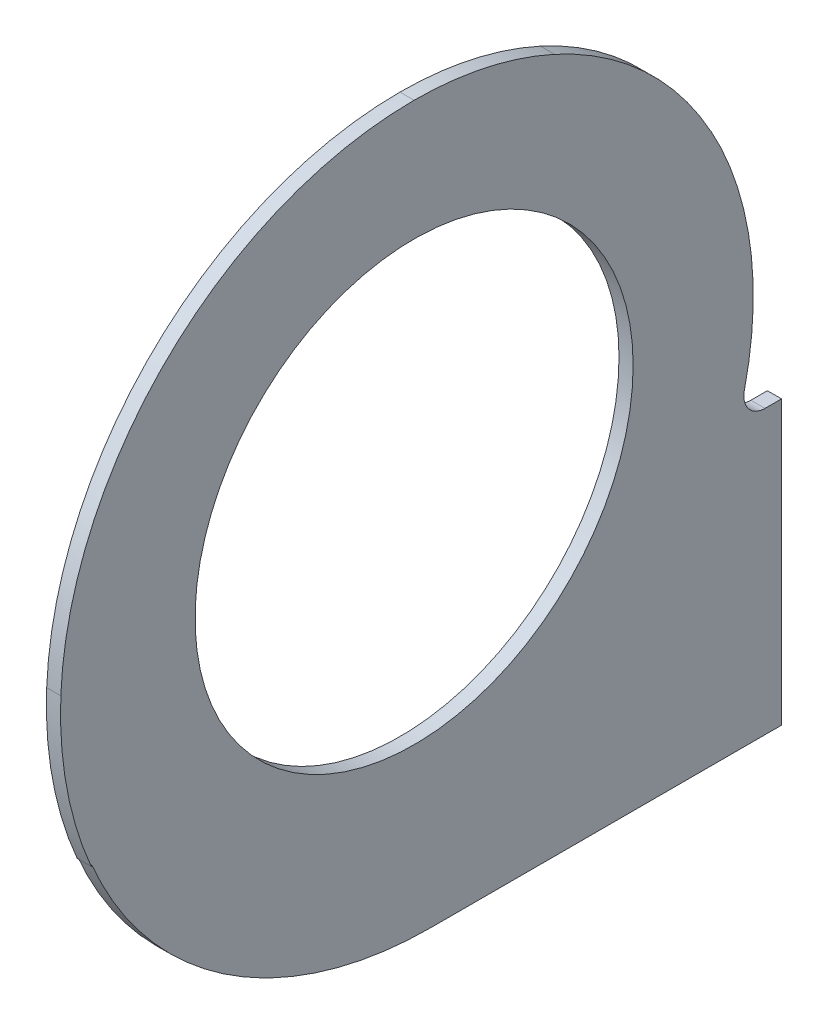
from build123d import *

# Parameters (mm, degrees)
BOSS_EXTRUDE1_DEPTH               = 11.5
BOSS_EXTRUDE2_DEPTH               = 11.5
SKETCH3_W                         = 11.5
SKETCH3_H                         = 20
BOSS_EXTRUDE3_DEPTH               = 2.000101203
CUT_EXTRUDE1_DEPTH                = 10.5
BOSS_EXTRUDE4_DEPTH               = 2
BOSS_EXTRUDE5_DEPTH               = 1
CUT_EXTRUDE2_DEPTH                = 10.5
CUT_EXTRUDE3_DEPTH                = 2
CUT_EXTRUDE4_DEPTH                = 0.5
CUT_EXTRUDE5_DEPTH                = 0.5
CUT_EXTRUDE6_DEPTH                = 0.5
CUT_EXTRUDE7_DEPTH                = 0.5
CUT_EXTRUDE8_DEPTH                = 0.5
CUT_EXTRUDE9_DEPTH                = 0.5
CUT_EXTRUDE10_DEPTH               = 0.5
CUT_EXTRUDE11_DEPTH               = 0.5
SKETCH17_W                        = 0.1
SKETCH17_H                        = 10.000000149
F_3_5_3_5_DIAMETER_HOLE1_D        = 3.5
F_3_5_3_5_DIAMETER_HOLE1_DEPTH    = 14.5
TAP_DRILL_FOR_M30_HELICOIL1_D     = 31
TAP_DRILL_FOR_M30_HELICOIL1_DEPTH = 1
FILLET1_R                         = 1.5
FILLET2_R                         = 2.5
SKETCH22_W                        = 77.458890367
SKETCH22_H                        = 66.182059073
CUT_EXTRUDE12_DEPTH               = 22
CUT_EXTRUDE13_DEPTH               = 22


with BuildPart() as part:
    # Sketch1 → Boss-Extrude1 (new body)
    with BuildSketch(Plane(origin=(14.5, 0, 0), x_dir=(0, 0, -1), z_dir=(1, 0, 0))):
        with BuildLine():
            Line((23.999898797, -14.052218991), (23.999898797, -7.3))
            Line((23.999898797, -7.3), (22.862851966, -7.3))
            ThreePointArc((22.862851966, -7.3), (23.515848466, 4.796339325), (18.177699617, 15.670712703))
            Line((18.177699617, 15.670712703), (20.247987256, 18.013406611))
            ThreePointArc((20.247987256, 18.013406611), (19.986593389, 22.247987256), (15.752012744, 21.986593389))
            Line((15.752012744, 21.986593389), (13.722435262, 19.689966239))
            ThreePointArc((13.722435262, 19.689966239), (7.191690005, 22.897152549), (0, 24))
            ThreePointArc((0, 24), (-17.327723451, 17.028878595), (-25, 0))
            ThreePointArc((-25, 0), (-23.695001808, -9.306968083), (-19.193077259, -17.556534771))
            Line((-19.193077259, -17.556534771), (-22.247987256, -21.013406611))
            ThreePointArc((-22.247987256, -21.013406611), (-21.986593389, -25.247987256), (-17.752012744, -24.986593389))
            Line((-17.752012744, -24.986593389), (-14.906270141, -21.766410971))
            ThreePointArc((-14.906270141, -21.766410971), (6.309457693, -26.79912492), (23.999898797, -14.052218991))
        make_face()
    extrude(amount=-BOSS_EXTRUDE1_DEPTH)

    # Sketch2 → Boss-Extrude2 (add)
    with BuildSketch(Plane(origin=(14.5, 0, 0), x_dir=(0, 0, -1), z_dir=(1, 0, 0))):
        with BuildLine():
            Line((1.208, -27.3), (23.999898797, -27.3))
            Line((23.999898797, -27.3), (23.999898797, -14.052218991))
            ThreePointArc((23.999898797, -14.052218991), (14.389183107, -23.747481674), (1.208, -27.3))
        make_face()
    extrude(amount=-BOSS_EXTRUDE2_DEPTH)

    # Sketch3 → Boss-Extrude3 (add)
    with BuildSketch(Plane(origin=(0, 0, -23.999898797), x_dir=(-1, 0, 0), z_dir=(0, 0, -1))):
        with Locations((-8.75, -17.3)):
            Rectangle(SKETCH3_W, SKETCH3_H)
    extrude(amount=BOSS_EXTRUDE3_DEPTH)

    # Sketch4 → Cut-Extrude1 (cut)
    with BuildSketch(Plane.ZY.offset(-3)):
        with BuildLine():
            Line((-2, 22.912878475), (-2, 11))
            Line((-2, 11), (2.00000006, 11))
            Line((2.00000006, 11), (2.00000006, 22.916594135))
            ThreePointArc((2.00000006, 22.916594135), (1.000869219, 22.979139476), (0, 23))
            ThreePointArc((0, 23), (-1.00094832, 22.978209296), (-2, 22.912878475))
        make_face()
    extrude(amount=-CUT_EXTRUDE1_DEPTH, mode=Mode.SUBTRACT)

    # Sketch5 → Boss-Extrude4 (add)
    with BuildSketch(Plane.ZY.offset(-3)):
        with BuildLine():
            Line((-2, 23.916521486), (-2, 11))
            Line((-2, 11), (2.00000006, 11))
            Line((2.00000006, 11), (2.00000006, 23.919938516))
            ThreePointArc((2.00000006, 23.919938516), (18.03582173, 16.321347476), (25, 0))
            ThreePointArc((25, 0), (23.695001808, -9.306968083), (19.193077259, -17.556534771))
            Line((19.193077259, -17.556534771), (22.247987256, -21.013406611))
            ThreePointArc((22.247987256, -21.013406611), (21.986593389, -25.247987256), (17.752012744, -24.986593389))
            Line((17.752012744, -24.986593389), (14.906270141, -21.766410971))
            ThreePointArc((14.906270141, -21.766410971), (7.31095401, -25.878060536), (-1.208, -27.3))
            Line((-1.208, -27.3), (-26, -27.3))
            Line((-26, -27.3), (-26, -7.3))
            Line((-26, -7.3), (-22.862851966, -7.3))
            ThreePointArc((-22.862851966, -7.3), (-23.515848466, 4.796339325), (-18.177699617, 15.670712703))
            Line((-18.177699617, 15.670712703), (-20.247987256, 18.013406611))
            ThreePointArc((-20.247987256, 18.013406611), (-19.986593389, 22.247987256), (-15.752012744, 21.986593389))
            Line((-15.752012744, 21.986593389), (-13.722435262, 19.689966239))
            ThreePointArc((-13.722435262, 19.689966239), (-8.140312338, 22.577318597), (-2, 23.916521486))
        make_face()
    extrude(amount=BOSS_EXTRUDE4_DEPTH)

    # Sketch6 → Boss-Extrude5 (add)
    with BuildSketch(Plane.ZY.offset(-1)):
        with BuildLine():
            Line((-2, 23.916521486), (-2, 11))
            Line((-2, 11), (2.00000006, 11))
            Line((2.00000006, 11), (2.00000006, 23.919938516))
            ThreePointArc((2.00000006, 23.919938516), (18.03582173, 16.321347476), (25, 0))
            ThreePointArc((25, 0), (23.695001808, -9.306968083), (19.193077259, -17.556534771))
            Line((19.193077259, -17.556534771), (22.247987256, -21.013406611))
            ThreePointArc((22.247987256, -21.013406611), (21.986593389, -25.247987256), (17.752012744, -24.986593389))
            Line((17.752012744, -24.986593389), (14.906270141, -21.766410971))
            ThreePointArc((14.906270141, -21.766410971), (7.31095401, -25.878060536), (-1.208, -27.3))
            Line((-1.208, -27.3), (-26, -27.3))
            Line((-26, -27.3), (-26, -7.3))
            Line((-26, -7.3), (-22.862851966, -7.3))
            ThreePointArc((-22.862851966, -7.3), (-23.515848466, 4.796339325), (-18.177699617, 15.670712703))
            Line((-18.177699617, 15.670712703), (-20.247987256, 18.013406611))
            ThreePointArc((-20.247987256, 18.013406611), (-19.986593389, 22.247987256), (-15.752012744, 21.986593389))
            Line((-15.752012744, 21.986593389), (-13.722435262, 19.689966239))
            ThreePointArc((-13.722435262, 19.689966239), (-8.140312338, 22.577318597), (-2, 23.916521486))
        make_face()
    extrude(amount=BOSS_EXTRUDE5_DEPTH)

    # Sketch7 → Cut-Extrude2 (cut)
    with BuildSketch(Plane(origin=(13.5, 0, 0), x_dir=(0, 0, -1), z_dir=(1, 0, 0))):
        with BuildLine():
            Line((2, 22.912878475), (2, 11))
            Line((2, 11), (-2.00000006, 11))
            Line((-2.00000006, 11), (-2.00000006, 22.916594135))
            ThreePointArc((-2.00000006, 22.916594135), (-17.342759411, 15.599308966), (-24.000832639, -0.040799334))
            ThreePointArc((-24.000832639, -0.040799334), (-16.992486688, -18.54262722), (1.208, -26.3))
            Line((1.208, -26.3), (26, -26.3))
            Line((26, -26.3), (26, -8.3))
            Line((26, -8.3), (21.450174824, -8.3))
            ThreePointArc((21.450174824, -8.3), (19.520210565, 12.163937664), (2, 22.912878475))
        make_face()
    extrude(amount=-CUT_EXTRUDE2_DEPTH, mode=Mode.SUBTRACT)

    # Sketch8 → Cut-Extrude3 (cut)
    with BuildSketch(Plane(origin=(3, 0, 0), x_dir=(0, 0, -1), z_dir=(1, 0, 0))):
        with BuildLine():
            Line((2, 22.912878475), (2, 11))
            Line((2, 11), (-2.00000006, 11))
            Line((-2.00000006, 11), (-2.00000006, 22.916594135))
            ThreePointArc((-2.00000006, 22.916594135), (-17.342759411, 15.599308966), (-24.000832639, -0.040799334))
            ThreePointArc((-24.000832639, -0.040799334), (-16.992486688, -18.54262722), (1.208, -26.3))
            Line((1.208, -26.3), (26, -26.3))
            Line((26, -26.3), (26, -8.3))
            Line((26, -8.3), (21.450174824, -8.3))
            ThreePointArc((21.450174824, -8.3), (19.520210565, 12.163937664), (2, 22.912878475))
        make_face()
    extrude(amount=-CUT_EXTRUDE3_DEPTH, mode=Mode.SUBTRACT)

    # Sketch9 → Cut-Extrude4 (cut)
    with BuildSketch(Plane.ZY):
        with BuildLine():
            Line((-0.5, -22.994564575), (-0.5, -10.988630488))
            ThreePointArc((-0.5, -10.988630488), (-4.209517756, -10.162674858), (-7.416581743, -8.123688525))
            Line((-7.416581743, -8.123688525), (-15.906059151, -16.613165932))
            ThreePointArc((-15.906059151, -16.613165932), (-8.801718944, -21.249229248), (-0.5, -22.994564575))
        make_face()
    extrude(amount=-CUT_EXTRUDE4_DEPTH, mode=Mode.SUBTRACT)

    # Sketch10 → Cut-Extrude5 (cut)
    with BuildSketch(Plane.ZY):
        with BuildLine():
            Line((-15.906059151, 16.613165932), (-7.416581743, 8.123688525))
            ThreePointArc((-7.416581743, 8.123688525), (-5.351481429, 9.610496684), (-3, 10.583005244))
            Line((-3, 10.583005244), (-3, 22.803508502))
            ThreePointArc((-3, 22.803508502), (-9.946851433, 20.737891565), (-15.906059151, 16.613165932))
        make_face()
    extrude(amount=-CUT_EXTRUDE5_DEPTH, mode=Mode.SUBTRACT)

    # Sketch11 → Cut-Extrude6 (cut)
    with BuildSketch(Plane.ZY):
        with BuildLine():
            Line((16.613165932, 15.906059151), (8.123688525, 7.416581743))
            ThreePointArc((8.123688525, 7.416581743), (10.162674858, 4.209517756), (10.988630488, 0.5))
            Line((10.988630488, 0.5), (22.994564575, 0.5))
            ThreePointArc((22.994564575, 0.5), (21.249229248, 8.801718944), (16.613165932, 15.906059151))
        make_face()
    extrude(amount=-CUT_EXTRUDE6_DEPTH, mode=Mode.SUBTRACT)

    # Sketch12 → Cut-Extrude7 (cut)
    with BuildSketch(Plane.ZY):
        with BuildLine():
            Line((-16.613165932, -15.906059151), (-8.123688525, -7.416581743))
            ThreePointArc((-8.123688525, -7.416581743), (-10.162674858, -4.209517756), (-10.988630488, -0.5))
            Line((-10.988630488, -0.5), (-22.994564575, -0.5))
            ThreePointArc((-22.994564575, -0.5), (-21.249229248, -8.801718944), (-16.613165932, -15.906059151))
        make_face()
    extrude(amount=-CUT_EXTRUDE7_DEPTH, mode=Mode.SUBTRACT)

    # Sketch13 → Cut-Extrude8 (cut)
    with BuildSketch(Plane.ZY):
        with BuildLine():
            Line((15.906059151, -16.613165932), (7.416581743, -8.123688525))
            ThreePointArc((7.416581743, -8.123688525), (4.209517756, -10.162674858), (0.5, -10.988630488))
            Line((0.5, -10.988630488), (0.5, -22.994564575))
            ThreePointArc((0.5, -22.994564575), (8.801718944, -21.249229248), (15.906059151, -16.613165932))
        make_face()
    extrude(amount=-CUT_EXTRUDE8_DEPTH, mode=Mode.SUBTRACT)

    # Sketch14 → Cut-Extrude9 (cut)
    with BuildSketch(Plane.ZY):
        with BuildLine():
            Line((3, 22.803508502), (3, 10.583005244))
            ThreePointArc((3, 10.583005244), (5.351481429, 9.610496684), (7.416581743, 8.123688525))
            Line((7.416581743, 8.123688525), (15.906059151, 16.613165932))
            ThreePointArc((15.906059151, 16.613165932), (9.946851433, 20.737891565), (3, 22.803508502))
        make_face()
    extrude(amount=-CUT_EXTRUDE9_DEPTH, mode=Mode.SUBTRACT)

    # Sketch15 → Cut-Extrude10 (cut)
    with BuildSketch(Plane.ZY):
        with BuildLine():
            Line((8.123688525, -7.416581743), (16.613165932, -15.906059151))
            ThreePointArc((16.613165932, -15.906059151), (21.249229248, -8.801718944), (22.994564575, -0.5))
            Line((22.994564575, -0.5), (10.988630488, -0.5))
            ThreePointArc((10.988630488, -0.5), (10.162674858, -4.209517756), (8.123688525, -7.416581743))
        make_face()
    extrude(amount=-CUT_EXTRUDE10_DEPTH, mode=Mode.SUBTRACT)

    # Sketch16 → Cut-Extrude11 (cut)
    with BuildSketch(Plane.ZY):
        with BuildLine():
            Line((-22.994564575, 0.5), (-10.988630488, 0.5))
            ThreePointArc((-10.988630488, 0.5), (-10.162674858, 4.209517756), (-8.123688525, 7.416581743))
            Line((-8.123688525, 7.416581743), (-16.613165932, 15.906059151))
            ThreePointArc((-16.613165932, 15.906059151), (-21.249229248, 8.801718944), (-22.994564575, 0.5))
        make_face()
    extrude(amount=-CUT_EXTRUDE11_DEPTH, mode=Mode.SUBTRACT)

    # Sketch17 → Cut-Revolve1 (revolve, cut)
    with BuildSketch(Plane(origin=(0, 0, 0), x_dir=(1, 0, 0), z_dir=(0, 1, 0))):
        with Locations((0.05, 5.000000074)):
            Rectangle(SKETCH17_W, SKETCH17_H)
    revolve(axis=Axis((0, 0, 0), (1, 0, 0)), mode=Mode.SUBTRACT)

    # Ø3.5 (3.5) Diameter Hole1
    with Locations(Plane.ZY):
        with Locations((-18, 20), (20, -23)):
            Hole(F_3_5_3_5_DIAMETER_HOLE1_D / 2, depth=F_3_5_3_5_DIAMETER_HOLE1_DEPTH)

    # Tap Drill for M30 Helicoil1
    with Locations(Plane(origin=(14.5, 0, 0), x_dir=(0, 0, -1), z_dir=(1, 0, 0))):
        with Locations((0, 0)):
            Hole(TAP_DRILL_FOR_M30_HELICOIL1_D / 2, depth=TAP_DRILL_FOR_M30_HELICOIL1_DEPTH)

    # Fillet1
    fillet1_edges = [part.edges().sort_by_distance(p)[0] for p in [
        (7.25, -7.3, -22.862851966),
    ]]
    fillet(fillet1_edges, radius=FILLET1_R)

    # Fillet2
    fillet2_edges = [part.edges().sort_by_distance(p)[0] for p in [
        (7.25, -8.3, -21.450174824),
        (7.25, -21.766410971, 14.906270141),
        (7.25, -17.556534771, 19.193077259),
        (7.25, 19.689966239, -13.722435262),
        (7.25, 15.670712703, -18.177699617),
    ]]
    fillet(fillet2_edges, radius=FILLET2_R)

    # Sketch22 → Cut-Extrude12 (cut)
    with BuildSketch(Plane.ZY.offset(-13.5)):
        with Locations((3.746075582, -1.742433044)):
            Rectangle(SKETCH22_W, SKETCH22_H)
    extrude(amount=CUT_EXTRUDE12_DEPTH, mode=Mode.SUBTRACT)

    # Sketch23 → Cut-Extrude13 (cut)
    with BuildSketch(Plane.ZY.offset(-13.5)):
        with BuildLine():
            Line((22.818301287, -11.435112892), (26.703674286, -25.778443436))
            Line((26.703674286, -25.778443436), (15.434056464, -28.831198071))
            Line((15.434056464, -28.831198071), (10.130861555, -24.722456157))
            ThreePointArc((10.130861555, -24.722456157), (17.689338268, -19.238696929), (22.818301287, -11.435112892))
        make_face()
        with BuildLine():
            Line((-9.783782243, 21.915234873), (-19.266917552, 25.788568278))
            Line((-19.266917552, 25.788568278), (-25.363017774, 18.892979502))
            Line((-25.363017774, 18.892979502), (-20.984828091, 11.618400961))
            ThreePointArc((-20.984828091, 11.618400961), (-16.224389467, 17.68067385), (-9.783782243, 21.915234873))
        make_face()
    extrude(amount=-CUT_EXTRUDE13_DEPTH, mode=Mode.SUBTRACT)


solid = part.part
